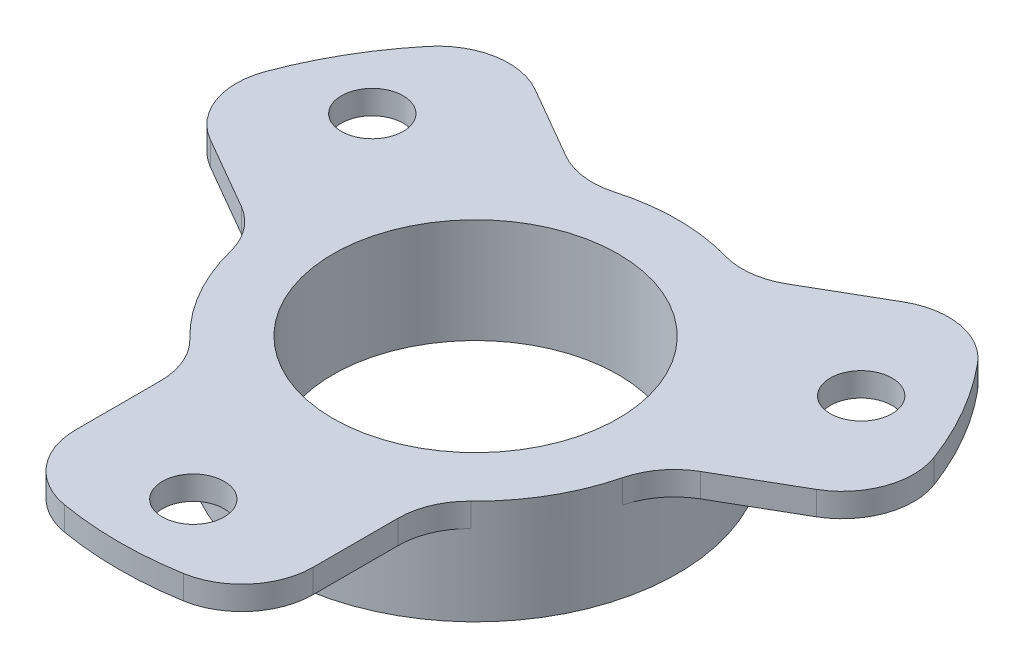
from build123d import *

# Parameters (mm, degrees)
TOP_VIEW_PATTERN_SKETCH_OUTSIDE_W = 104.696
TOP_VIEW_PATTERN_SKETCH_OUTSIDE_H = 104.696
TOP_VIEW_PATTERN_SKETCH_OUTSIDE_R = 6
CUT_EXTRUDE1_DEPTH                = 15
F_4_0MM_DOWEL_HOLE1_D             = 5.2


with BuildPart() as part:
    # Sketch2 → Revolve1 (revolve)
    with BuildSketch(Plane.XY):
        Polygon((-40, 0), (-17, 0), (-17, -6.8), (-15.5, -6.8), (-15.5, 0), (-13.5, 0), (-13.5, -6.8), (-12, -6.8), (-12, 2), (-40, 2), align=None)
    revolve(axis=Axis((0, 30.077146874, 0), (0, -1, 0)))

    # Top View Pattern Sketch outside → Cut-Extrude1 (cut, symmetric)
    with BuildSketch(Plane(origin=(0, 0, 0), x_dir=(1, 0, 0), z_dir=(0, 1, 0))):
        Rectangle(TOP_VIEW_PATTERN_SKETCH_OUTSIDE_W, TOP_VIEW_PATTERN_SKETCH_OUTSIDE_H)
        with BuildLine():
            Line((-10, -23.664319132), (-10, -16.522711642))
            ThreePointArc((-10, -16.522711642), (-10.475351674, -14.182143149), (-11.826086957, -12.21243904))
            ThreePointArc((-11.826086957, -12.21243904), (-14.722431864, -8.5), (-16.489325929, -4.135472212))
            ThreePointArc((-16.489325929, -4.135472212), (-17.519772084, -1.980849088), (-19.309088021, -0.398898217))
            Line((-19.309088021, -0.398898217), (-25.493901532, 3.171905528))
            ThreePointArc((-25.493901532, 3.171905528), (-28.139291346, 6.335922658), (-28.117376915, 10.460072439))
            ThreePointArc((-28.117376915, 10.460072439), (-25.980762114, 15), (-23.117376915, 19.120326477))
            ThreePointArc((-23.117376915, 19.120326477), (-19.556715651, 21.201379821), (-15.493901532, 20.492413604))
            Line((-15.493901532, 20.492413604), (-9.309088021, 16.921609859))
            ThreePointArc((-9.309088021, 16.921609859), (-7.04442041, 16.162992237), (-4.663238972, 16.347911252))
            ThreePointArc((-4.663238972, 16.347911252), (0, 17), (4.663238972, 16.347911252))
            ThreePointArc((4.663238972, 16.347911252), (7.04442041, 16.162992237), (9.309088021, 16.921609859))
            Line((9.309088021, 16.921609859), (15.493901532, 20.492413604))
            ThreePointArc((15.493901532, 20.492413604), (19.556715651, 21.201379821), (23.117376915, 19.120326477))
            ThreePointArc((23.117376915, 19.120326477), (25.980762114, 15), (28.117376915, 10.460072439))
            ThreePointArc((28.117376915, 10.460072439), (28.139291346, 6.335922658), (25.493901532, 3.171905528))
            Line((25.493901532, 3.171905528), (19.309088021, -0.398898217))
            ThreePointArc((19.309088021, -0.398898217), (17.519772084, -1.980849088), (16.489325929, -4.135472212))
            ThreePointArc((16.489325929, -4.135472212), (14.722431864, -8.5), (11.826086957, -12.21243904))
            ThreePointArc((11.826086957, -12.21243904), (10.475351674, -14.182143149), (10, -16.522711642))
            Line((10, -16.522711642), (10, -23.664319132))
            ThreePointArc((10, -23.664319132), (8.582575695, -27.537302479), (5, -29.580398915))
            ThreePointArc((5, -29.580398915), (0, -30), (-5, -29.580398915))
            ThreePointArc((-5, -29.580398915), (-8.582575695, -27.537302479), (-10, -23.664319132))
        make_face(mode=Mode.SUBTRACT)
        Circle(TOP_VIEW_PATTERN_SKETCH_OUTSIDE_R)
    extrude(amount=CUT_EXTRUDE1_DEPTH, both=True, mode=Mode.SUBTRACT)

    # Ø4.0mm Dowel Hole1 (through all)
    with Locations(Plane(origin=(0, 0, 0), x_dir=(-1, 0, 0), z_dir=(0, -1, 0))):
        with Locations((0, -23.75), (20.56810334, 11.875), (-20.56810334, 11.875)):
            Hole(F_4_0MM_DOWEL_HOLE1_D / 2)


solid = part.part
